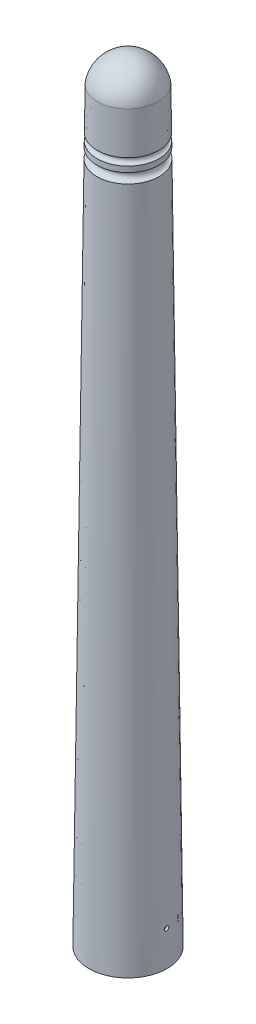
from build123d import *

# Parameters (mm, degrees)
FURO1_D     = 0.51
FURO1_DEPTH = 0.3
FURO2_D     = 0.51
FURO2_DEPTH = 0.3


with BuildPart() as part:
    # Esboço1 → Revolução1 (revolve)
    with BuildSketch(Plane(origin=(0, 0, 0), x_dir=(-1, 0, 0), z_dir=(0, 0, -1))):
        with BuildLine():
            Line((-4.5, -86), (0, -86))
            Line((0, -86), (0, 3))
            ThreePointArc((0, 3), (-2.304886114, 2.147367133), (-3.5, 0))
            Line((-3.5, 0), (-3.556244043, -4.836987738))
            ThreePointArc((-3.556244043, -4.836987738), (-3.146810303, -5.256055213), (-3.565877779, -5.665488953))
            Line((-3.565877779, -5.665488953), (-3.573349728, -6.308076594))
            ThreePointArc((-3.573349728, -6.308076594), (-2.992535071, -6.883118814), (-3.586563954, -7.444500063))
            Line((-3.586563954, -7.444500063), (-4.5, -86))
        make_face()
    revolve(axis=Axis((0, -86, 0), (0, 1, 0)))

    # Esboço3 → Corte-Revolução1 (revolve, cut)
    with BuildSketch(Plane(origin=(0, 0, 0), x_dir=(-1, 0, 0), z_dir=(0, 0, -1))):
        with BuildLine():
            Line((-1.412587892, -78.5), (0, -78.5))
            Line((0, -78.5), (0, 0))
            ThreePointArc((0, 0), (-0.304633385, -0.093781326), (-0.503781516, -0.342651689))
            Line((-0.503781516, -0.342651689), (-1.412587892, -78.5))
        make_face()
    revolve(axis=Axis((0, -78.5, 0), (0, 1, 0)), mode=Mode.SUBTRACT)

    # Furo1
    with Locations(Plane(origin=(-4.453448829, -81.996599309, 0), x_dir=(-0.011627121, -0.999932403, 0), z_dir=(-0.999932403, 0.011627121, 0))):
        with Locations((0, 0)):
            Hole(FURO1_D / 2, depth=FURO1_DEPTH)

    # Furo2
    with Locations(Plane(origin=(4.453448829, -81.996599309, 0), x_dir=(-0.011627121, 0.999932403, 0), z_dir=(0.999932403, 0.011627121, 0))):
        with Locations((0, 0)):
            Hole(FURO2_D / 2, depth=FURO2_DEPTH)


solid = part.part
